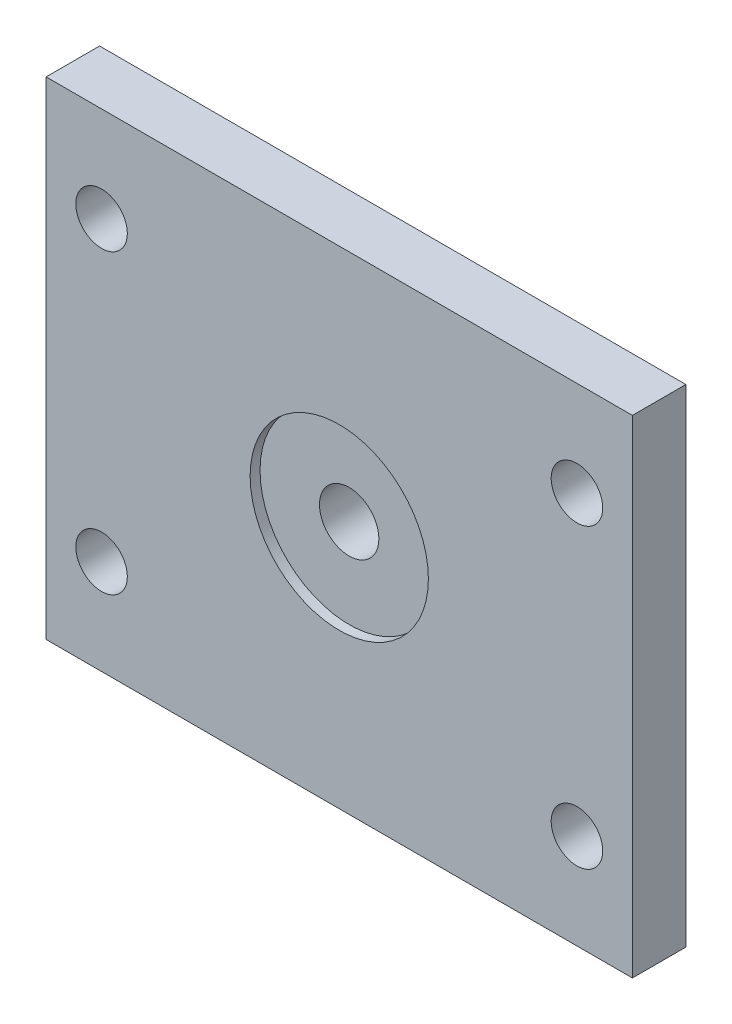
from build123d import *

# Parameters (mm, degrees)
SKETCH1_W      = 296
SKETCH1_H      = 246
SKETCH1_R      = 13
EXTRUDE1_DEPTH = 27
SKETCH2_R      = 45
EXTRUDE2_DEPTH = 5
SKETCH3_R      = 15
EXTRUDE3_DEPTH = 23


with BuildPart() as part:
    # Sketch1 → Extrude1 (new body)
    with BuildSketch(Plane.XY):
        Rectangle(SKETCH1_W, SKETCH1_H)
        with Locations((-120, 75)):
            Circle(SKETCH1_R, mode=Mode.SUBTRACT)
        with Locations((120, 75)):
            Circle(SKETCH1_R, mode=Mode.SUBTRACT)
        with Locations((120, -75)):
            Circle(SKETCH1_R, mode=Mode.SUBTRACT)
        with Locations((-120, -75)):
            Circle(SKETCH1_R, mode=Mode.SUBTRACT)
    extrude(amount=EXTRUDE1_DEPTH)

    # Sketch2 → Extrude2 (cut)
    with BuildSketch(Plane(origin=(0, 0, 27), x_dir=(-1, 0, 0), z_dir=(0, 0, -1))):
        Circle(SKETCH2_R)
    extrude(amount=EXTRUDE2_DEPTH, mode=Mode.SUBTRACT)

    # Sketch3 → Extrude3 (cut, through all)
    with BuildSketch(Plane.XY.offset(22)):
        Circle(SKETCH3_R)
    extrude(amount=-EXTRUDE3_DEPTH, mode=Mode.SUBTRACT)


solid = part.part
